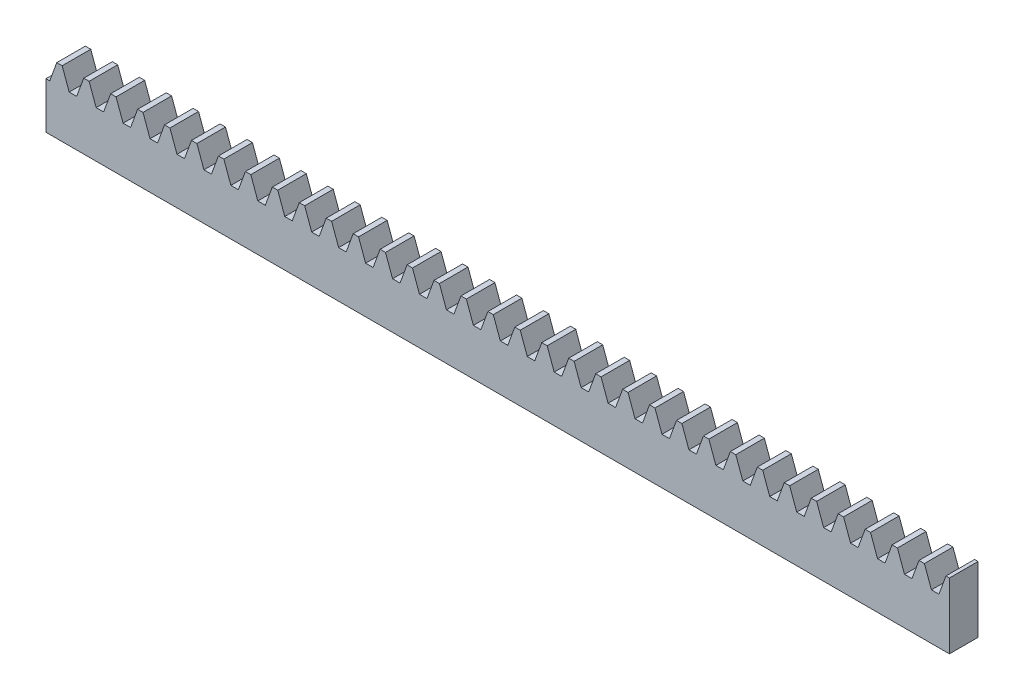
from build123d import *

# Parameters (mm, degrees)
BLANKSKE_W        = 158
BLANKSKE_H        = 11.5
BLANK_DEPTH       = 5
TOOTHCUTSIM_DEPTH = 159.496845394
TEETHCUTS_COUNT   = 34
TEETHCUTS_PITCH   = 4.712388975


with BuildPart() as part:
    # BlankSke → Blank (new body)
    with BuildSketch(Plane.XY):
        with Locations((79, 5.75)):
            Rectangle(BLANKSKE_W, BLANKSKE_H)
    extrude(amount=-BLANK_DEPTH)

    # TooCutSkeSim → ToothCutSim (cut, through all)
    with BuildSketch(Plane.XY):
        Polygon((0.654653055, 8.125), (-0.654653055, 8.125), (-1.892297439, 11.5254), (1.892297439, 11.5254), align=None)
    toothcutsim = extrude(amount=-TOOTHCUTSIM_DEPTH, mode=Mode.SUBTRACT)

    # TeethCuts: ToothCutSim ×34
    with Locations(*[(i * TEETHCUTS_PITCH, 0, 0) for i in range(1, TEETHCUTS_COUNT)]):
        add(toothcutsim, mode=Mode.SUBTRACT)


solid = part.part
